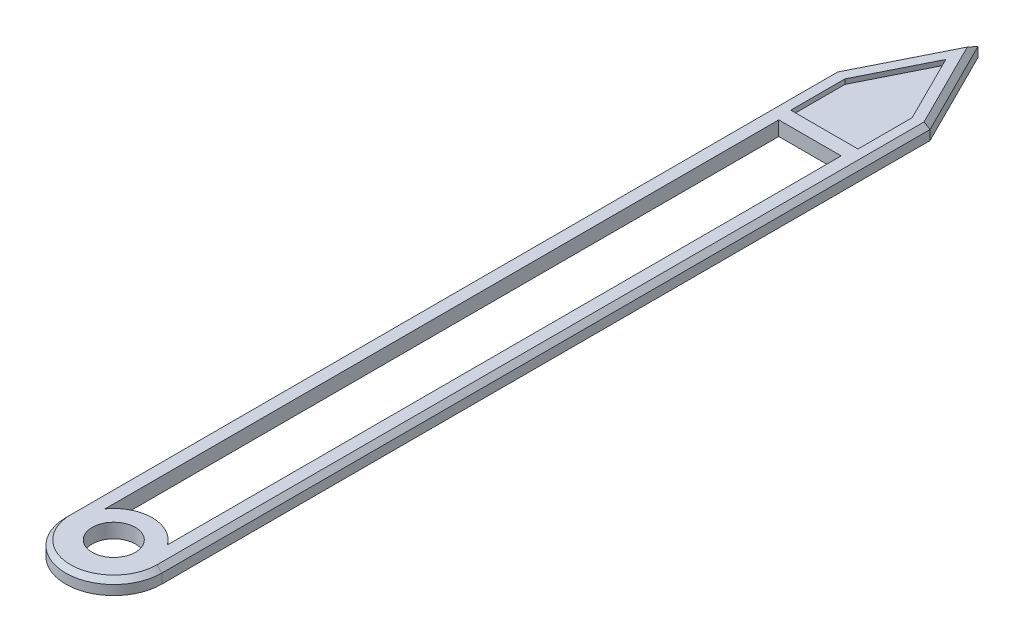
from build123d import *

# Parameters (mm, degrees)
SKETCH1_R           = 0.45
BOSS_EXTRUDE1_DEPTH = 0.3
CUT_EXTRUDE1_DEPTH  = 0.1
CHAMFER1_SIZE       = 0.1


with BuildPart() as part:
    # Sketch1 → Boss-Extrude1 (new body)
    with BuildSketch(Plane(origin=(0, 0, 0), x_dir=(1, 0, 0), z_dir=(0, 1, 0))):
        with BuildLine():
            Line((-1, 0), (-1, 16))
            Line((-1, 16), (0, 18))
            Line((0, 18), (1, 16))
            Line((1, 16), (1, 0))
            ThreePointArc((1, 0), (0, -1), (-1, 0))
        make_face()
        Circle(SKETCH1_R, mode=Mode.SUBTRACT)
        with BuildLine():
            Line((-0.65, 0.466368953), (-0.65, 14.5))
            Line((-0.65, 14.5), (0.65, 14.5))
            Line((0.65, 14.5), (0.65, 0.466368953))
            ThreePointArc((0.65, 0.466368953), (0, 0.8), (-0.65, 0.466368953))
        make_face(mode=Mode.SUBTRACT)
    extrude(amount=BOSS_EXTRUDE1_DEPTH)

    # Sketch2 → Cut-Extrude1 (cut)
    with BuildSketch(Plane(origin=(0, 0.3, 0), x_dir=(1, 0, 0), z_dir=(0, 1, 0))):
        Polygon((-0.7, 15.929179607), (-0.7, 14.8), (0.7, 14.8), (0.7, 15.929179607), (0, 17.329179607), align=None)
    extrude(amount=-CUT_EXTRUDE1_DEPTH, mode=Mode.SUBTRACT)

    # Chamfer1
    chamfer1_edges = [part.edges().sort_by_distance(p)[0] for p in [
        (0.5, 0.3, -17),
        (-0.5, 0.3, -17),
        (-1, 0.3, -8),
        (0, 0.3, 1),
        (1, 0.3, -8),
    ]]
    chamfer(chamfer1_edges, length=CHAMFER1_SIZE)


solid = part.part
